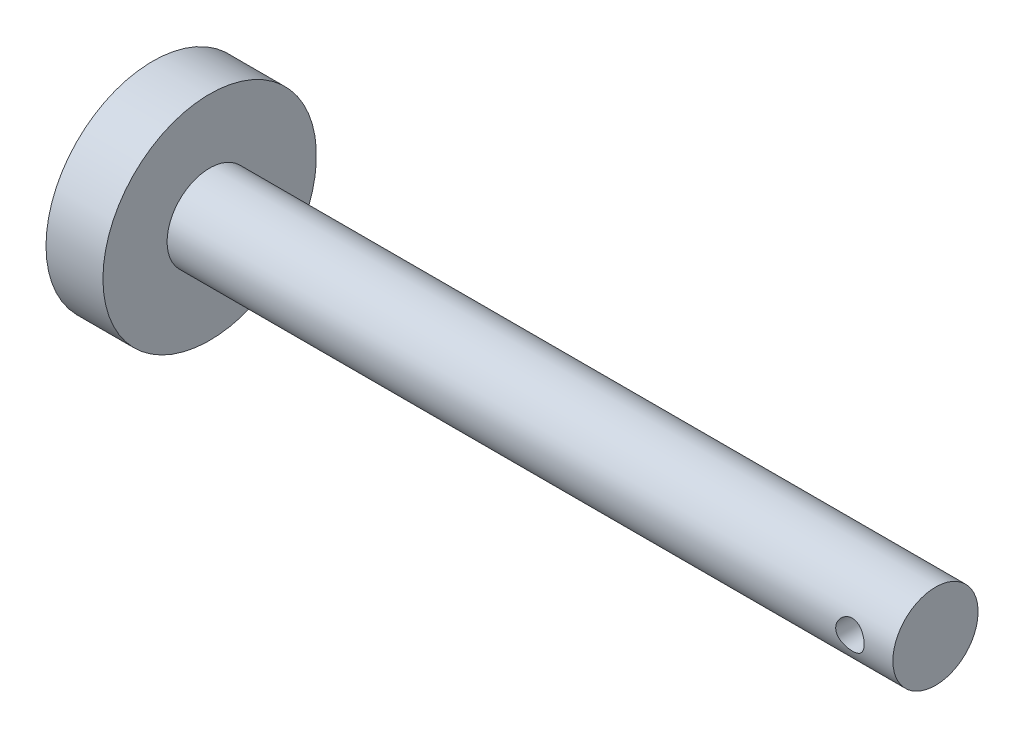
from build123d import *

# Parameters (mm, degrees)
SKETCH2_R               = 1
CUT_EXTRUDE2_DEPTH      = 8.5
CUT_EXTRUDE2_DEPTH_BACK = 8.5


with BuildPart() as part:
    # Sketch1 → Revolve2 (revolve)
    with BuildSketch(Plane.XY):
        Polygon((-16.067192276, 0), (38.932807724, 0), (38.932807724, 2.992227979), (-12.067192276, 2.992227979), (-12.067192276, 7.5), (-16.067192276, 7.5), align=None)
    revolve(axis=Axis((-16.067192276, 0, 0), (1, 0, 0)))

    # Sketch2 → Cut-Extrude2 (cut, two sides)
    with BuildSketch(Plane.XY) as cut_extrude2_sk:
        with Locations((35.91188951, 0)):
            Circle(SKETCH2_R)
    extrude(amount=CUT_EXTRUDE2_DEPTH, mode=Mode.SUBTRACT)
    extrude(cut_extrude2_sk.sketch, amount=-CUT_EXTRUDE2_DEPTH_BACK, mode=Mode.SUBTRACT)


solid = part.part
